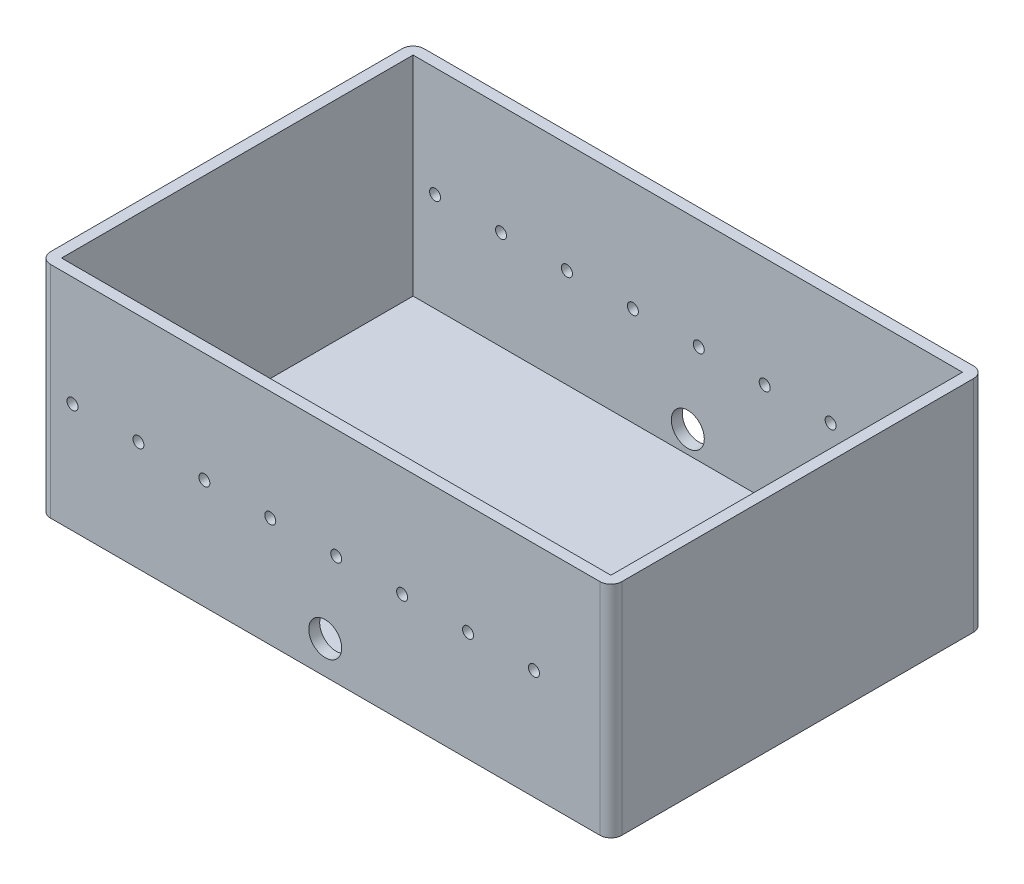
from build123d import *

# Parameters (mm, degrees)
SKETCH1_W           = 170
SKETCH1_H           = 100
BOSS_EXTRUDE1_DEPTH = 130
SKETCH1_3_W         = 160
SKETCH1_3_H         = 95
CUT_EXTRUDE1_DEPTH  = 125
FILLET1_R           = 5
SKETCH2_R           = 2.5
CUT_EXTRUDE2_DEPTH  = 237.22023622
SKETCH3_R           = 7.5
CUT_EXTRUDE3_DEPTH  = 237.22023622


with BuildPart() as part:
    # Sketch1 → Boss-Extrude1 (new, symmetric)
    with BuildSketch(Plane(origin=(0, 0, 0), x_dir=(0, 0, -1), z_dir=(1, 0, 0))):
        with Locations((-85, 50)):
            Rectangle(SKETCH1_W, SKETCH1_H)
    extrude(amount=BOSS_EXTRUDE1_DEPTH, both=True)

    # Sketch1_3 → Cut-Extrude1 (cut, symmetric)
    with BuildSketch(Plane(origin=(0, 0, 0), x_dir=(0, 0, -1), z_dir=(1, 0, 0))):
        with Locations((-85, 52.5)):
            Rectangle(SKETCH1_3_W, SKETCH1_3_H)
    extrude(amount=CUT_EXTRUDE1_DEPTH, both=True, mode=Mode.SUBTRACT)

    # Fillet1
    fillet1_edges = [part.edges().sort_by_distance(p)[0] for p in [
        (-130, 50, 0),
        (130, 50, 0),
        (-130, 50, 170),
        (130, 50, 170),
    ]]
    fillet(fillet1_edges, radius=FILLET1_R)

    # Sketch2 → Cut-Extrude2 (cut, through all)
    with BuildSketch(Plane.XY.offset(170)):
        with Locations((95, 50)):
            Circle(SKETCH2_R)
        with Locations((65, 50)):
            Circle(SKETCH2_R)
        with Locations((35, 50)):
            Circle(SKETCH2_R)
        with Locations((5, 50)):
            Circle(SKETCH2_R)
        with Locations((-25, 50)):
            Circle(SKETCH2_R)
        with Locations((-55, 50)):
            Circle(SKETCH2_R)
        with Locations((-85, 50)):
            Circle(SKETCH2_R)
        with Locations((-115, 50)):
            Circle(SKETCH2_R)
    extrude(amount=-CUT_EXTRUDE2_DEPTH, mode=Mode.SUBTRACT)

    # Sketch3 → Cut-Extrude3 (cut, through all)
    with BuildSketch(Plane.XY.offset(170)):
        with Locations((0, 15)):
            Circle(SKETCH3_R)
    extrude(amount=-CUT_EXTRUDE3_DEPTH, mode=Mode.SUBTRACT)


solid = part.part
